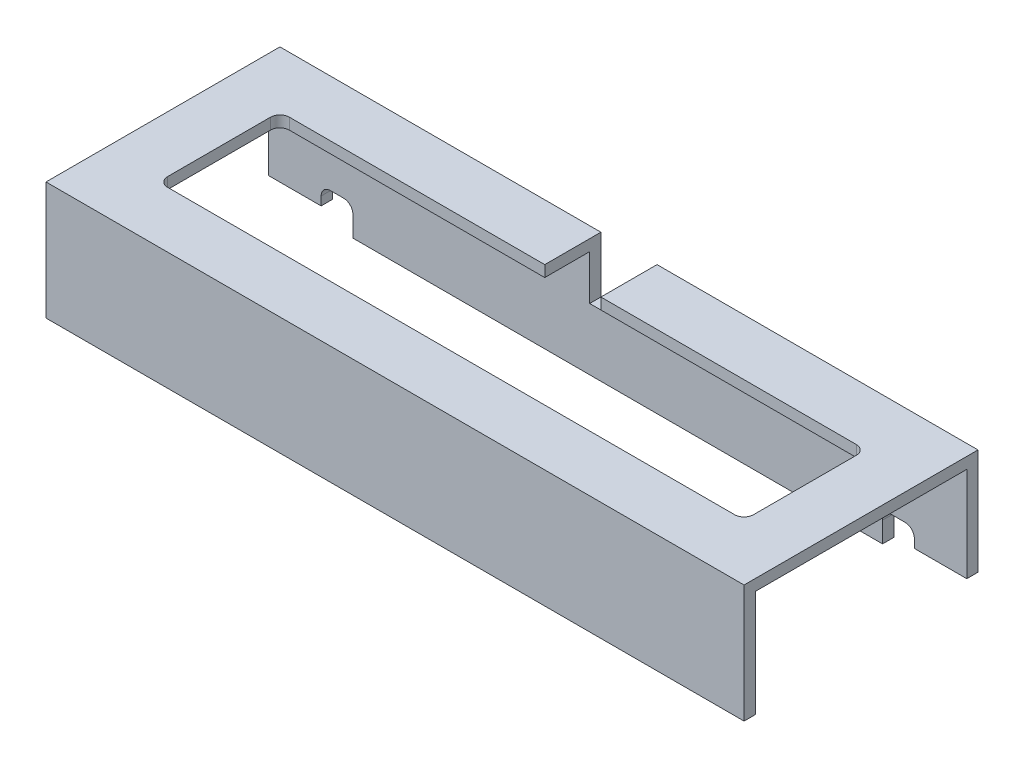
from build123d import *

# Parameters (mm, degrees)
BOSS_EXTRUDE1_DEPTH      = 311.5
BOSS_EXTRUDE1_DEPTH_BACK = 61.5
SKETCH2_R                = 4.34
SKETCH2_W                = 30
SKETCH2_H                = 24
SKETCH2_H_2              = 6
CORTAR_EXTRUIR1_DEPTH    = 30
CORTAR_EXTRUIR3_REACH    = 65
REDONDEO1_R              = 5


with BuildPart() as part:
    # Sketch1 → Boss-Extrude1 (new body, two sides)
    with BuildSketch(Plane(origin=(0, 0, 0), x_dir=(0, 0, -1), z_dir=(1, 0, 0))) as boss_extrude1_sk:
        Polygon((0, 0), (6, 0), (6, 57), (119, 57), (119, 0), (125, 0), (125, 63), (0, 63), align=None)
    extrude(amount=BOSS_EXTRUDE1_DEPTH)
    extrude(boss_extrude1_sk.sketch, amount=-BOSS_EXTRUDE1_DEPTH_BACK)

    # Sketch2 → Cortar-Extruir1 (cut)
    with BuildSketch(Plane(origin=(0, 0, -125), x_dir=(-1, 0, 0), z_dir=(0, 0, -1))):
        Polygon((-311.5, 0), (-266.5, 0), (-266.5, 16), (-283.5, 16), (-283.5, 6.4), (-311.5, 6.4), align=None)
        with Locations((-277.52, 10.9)):
            Circle(SKETCH2_R, mode=Mode.SUBTRACT)
        with Locations((-277.52, 10.9)):
            Circle(SKETCH2_R)
        with Locations((-125, 45)):
            Rectangle(SKETCH2_W, SKETCH2_H)
        with Locations((-125, 60)):
            Rectangle(SKETCH2_W, SKETCH2_H_2)
        Polygon((16.5, 16), (16.5, 0), (61.5, 0), (61.5, 6.4), (33.5, 6.4), (33.5, 16), align=None)
    extrude(amount=-CORTAR_EXTRUIR1_DEPTH, mode=Mode.SUBTRACT)

    # Croquis1 → Cortar-Extruir3 (cut, up to next)
    with BuildSketch(Plane(origin=(0, 63, 0), x_dir=(1, 0, 0), z_dir=(0, 1, 0)), mode=Mode.PRIVATE) as cortar_extruir3_sk1:
        Polygon((-31.5, 95), (-31.5, 30), (281.5, 30), (281.5, 95), (170, 95), (140, 95), (110, 95), (80, 95), align=None)
    cortar_extruir3_tool1 = extrude(cortar_extruir3_sk1.sketch, amount=-CORTAR_EXTRUIR3_REACH, mode=Mode.PRIVATE) & part.part
    add(cortar_extruir3_tool1.solids().sort_by_distance((125, 63, -62.5))[0], mode=Mode.SUBTRACT)

    # Redondeo1
    redondeo1_edges = [part.edges().sort_by_distance(p)[0] for p in [
        (-16.5, 16, -122),
        (-33.5, 16, -122),
        (-31.5, 60, -95),
        (281.5, 60, -95),
        (281.5, 60, -30),
        (-31.5, 60, -30),
        (283.5, 16, -122),
        (266.5, 16, -122),
    ]]
    fillet(redondeo1_edges, radius=REDONDEO1_R)


solid = part.part
